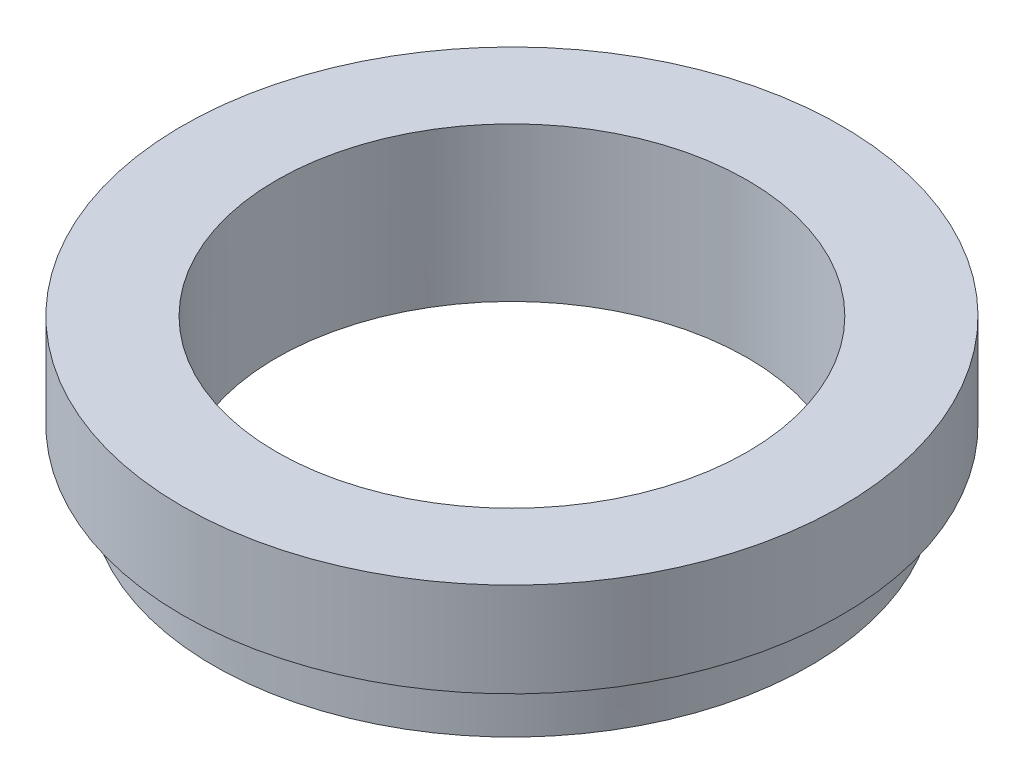
from build123d import *

# Parameters (mm, degrees)
SCHIZZO1_R                   = 9.5
SCHIZZO1_R_2                 = 7.5
ESTRUSIONE_ESTRUSIONE1_DEPTH = 5
SCHIZZO2_R                   = 10.5
SCHIZZO2_R_2                 = 9.5
ESTRUSIONE_ESTRUSIONE2_DEPTH = 3
SCHIZZO3_R                   = 9.5
TAGLIO_ESTRUSIONE1_DEPTH     = 0.1


with BuildPart() as part:
    # Schizzo1 → Estrusione-Estrusione1 (new body)
    with BuildSketch(Plane(origin=(0, 0, 0), x_dir=(1, 0, 0), z_dir=(0, 1, 0))):
        Circle(SCHIZZO1_R)
        Circle(SCHIZZO1_R_2, mode=Mode.SUBTRACT)
    extrude(amount=ESTRUSIONE_ESTRUSIONE1_DEPTH)

    # Schizzo2 → Estrusione-Estrusione2 (add)
    with BuildSketch(Plane(origin=(0, 5, 0), x_dir=(1, 0, 0), z_dir=(0, 1, 0))):
        Circle(SCHIZZO2_R)
        Circle(SCHIZZO2_R_2, mode=Mode.SUBTRACT)
    extrude(amount=-ESTRUSIONE_ESTRUSIONE2_DEPTH)

    # Schizzo3 → Taglio-Estrusione1 (cut)
    with BuildSketch(Plane.XZ):
        Circle(SCHIZZO3_R)
    extrude(amount=-TAGLIO_ESTRUSIONE1_DEPTH, mode=Mode.SUBTRACT)


solid = part.part
